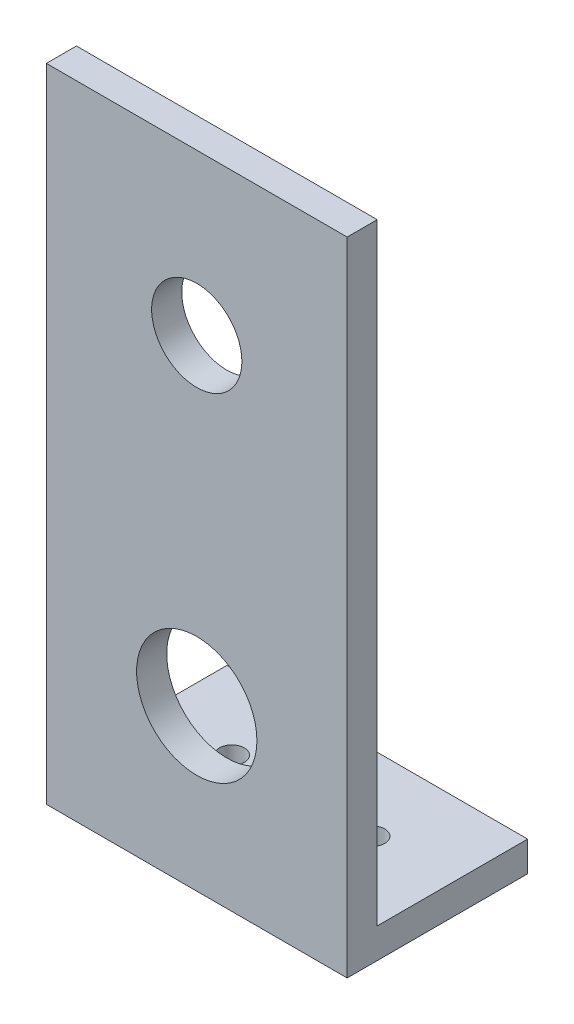
from build123d import *

# Parameters (mm, degrees)
SKETCH1_W           = 30
SKETCH1_H           = 64
BOSS_EXTRUDE1_DEPTH = 3
SKETCH2_R           = 4.5
SKETCH2_R_2         = 6
CUT_EXTRUDE1_DEPTH  = 3
SKETCH4_W           = 30
SKETCH4_H           = 3
BOSS_EXTRUDE3_DEPTH = 15
SKETCH5_R           = 1.25
CUT_EXTRUDE2_DEPTH  = 15


with BuildPart() as part:
    # Sketch1 → Boss-Extrude1 (new body)
    with BuildSketch(Plane.XY):
        with Locations((-16.801372712, 6.218640229)):
            Rectangle(SKETCH1_W, SKETCH1_H)
    extrude(amount=BOSS_EXTRUDE1_DEPTH)

    # Sketch2 → Cut-Extrude1 (cut)
    with BuildSketch(Plane.XY.offset(3)):
        with Locations((-16.801372712, 22.218640229)):
            Circle(SKETCH2_R)
        with Locations((-16.801372712, -9.781359771)):
            Circle(SKETCH2_R_2)
    extrude(amount=-CUT_EXTRUDE1_DEPTH, mode=Mode.SUBTRACT)

    # Sketch4 → Boss-Extrude3 (add)
    with BuildSketch(Plane(origin=(0, 0, 0), x_dir=(-1, 0, 0), z_dir=(0, 0, -1))):
        with Locations((16.801372712, -24.281359771)):
            Rectangle(SKETCH4_W, SKETCH4_H)
    extrude(amount=BOSS_EXTRUDE3_DEPTH)

    # Sketch5 → Cut-Extrude2 (cut)
    with BuildSketch(Plane(origin=(0, -22.781359771, 0), x_dir=(1, 0, 0), z_dir=(0, 1, 0))):
        with Locations((-9.801372712, 7.5)):
            Circle(SKETCH5_R)
        with Locations((-23.801372712, 7.5)):
            Circle(SKETCH5_R)
    extrude(amount=-CUT_EXTRUDE2_DEPTH, mode=Mode.SUBTRACT)


solid = part.part
